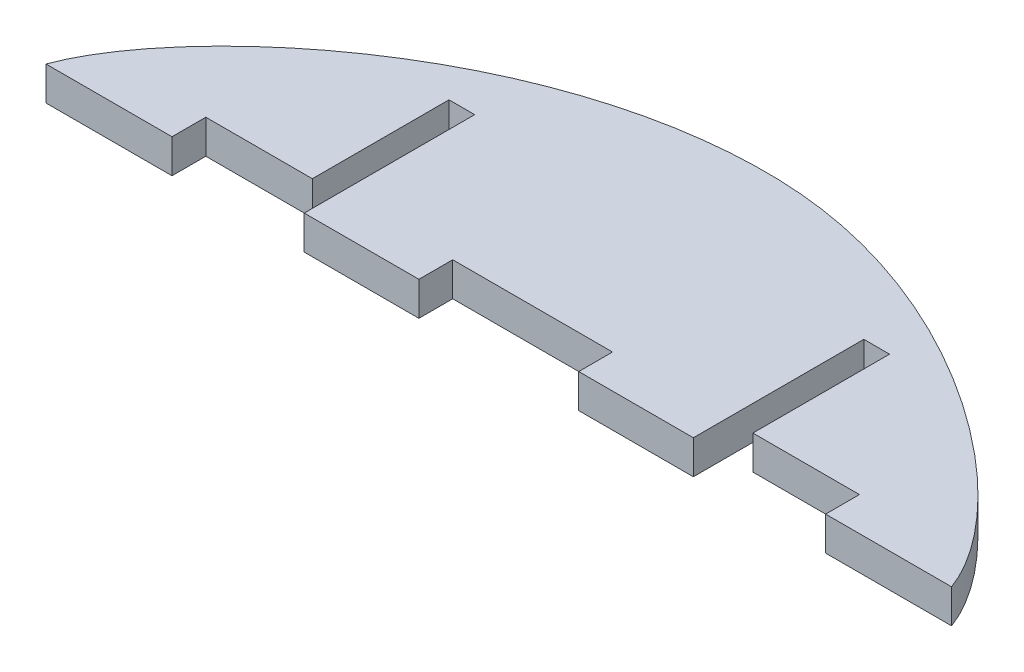
from build123d import *

# Parameters (mm, degrees)
BOSS_EXTRUDE1_DEPTH = 3.175
SKETCH2_W           = 10
SKETCH2_H           = 3.175
SKETCH2_W_2         = 15
CUT_EXTRUDE1_DEPTH  = 4.1750001


with BuildPart() as part:
    # Sketch1 → Boss-Extrude1 (new body)
    with BuildSketch(Plane(origin=(0, 0, 0), x_dir=(1, 0, 0), z_dir=(0, 1, 0))):
        with BuildLine():
            add(Edge.make_bspline(
                [(0, 0), (3.07818129, 8.457233587), (19.262118608, 23.397882677), (40.36741362, 25), (42.5, 25)],
                knots=[0, 0, 0, 0, 0.479831935, 0.533146595, 0.533146595, 0.533146595, 0.533146595], degree=3))
            Line((0, 0), (42.5, 0))
            Line((42.5, 0), (42.5, 25))
        make_face()
        with BuildLine():
            Line((42.5, 25), (42.5, 0))
            Line((42.5, 0), (85, 0))
            add(Edge.make_bspline(
                [(42.5, 25), (44.36741362, 25), (63.21067639, 23.77153695), (81.92181871, 8.457233587), (85, 0)],
                knots=[0.533146595, 0.533146595, 0.533146595, 0.533146595, 0.579831935, 1, 1, 1, 1], degree=3))
        make_face()
    extrude(amount=BOSS_EXTRUDE1_DEPTH)

    # Sketch2 → Cut-Extrude1 (cut, through all)
    with BuildSketch(Plane.XZ):
        with Locations((68.175, -1.5875)):
            Rectangle(SKETCH2_W, SKETCH2_H)
        Polygon((60.762, 0), (60.762, -16), (63.175, -16), (63.175, -3.175), (63.175, 0), align=None)
        with Locations((42.5, -1.5875)):
            Rectangle(SKETCH2_W_2, SKETCH2_H)
        Polygon((24.238, -16), (24.238, 0), (21.825, 0), (21.825, -3.175), (21.825, -16), align=None)
        with Locations((16.825, -1.5875)):
            Rectangle(SKETCH2_W, SKETCH2_H)
    extrude(amount=-CUT_EXTRUDE1_DEPTH, mode=Mode.SUBTRACT)


solid = part.part
